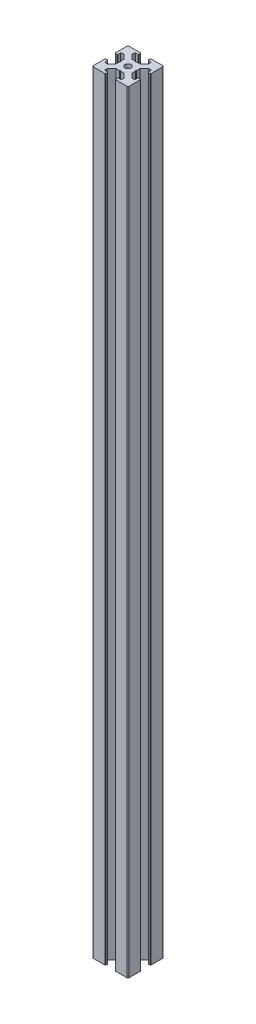
from build123d import *

# Parameters (mm, degrees)
BOSS_EXTRUDE1_DEPTH = 649
FILLET1_R           = 1
SKETCH4_R           = 2.5
CUT_EXTRUDE1_DEPTH  = 650
FILLET2_R           = 0.5


with BuildPart() as part:
    # Sketch3 → Boss-Extrude1 (new body)
    with BuildSketch(Plane(origin=(0, 0, 0), x_dir=(1, 0, 0), z_dir=(0, 1, 0))):
        with BuildLine():
            Line((11, 27.75), (11, 29.5))
            ThreePointArc((11, 29.5), (10.646446609, 29.646446609), (10.5, 30))
            Line((10.5, 30), (0, 30))
            Line((0, 30), (0, 19.5))
            ThreePointArc((0, 19.5), (0.353553391, 19.353553391), (0.5, 19))
            Line((0.5, 19), (2.25, 19))
            Line((2.25, 19), (2.25, 22))
            Line((2.25, 22), (4.5, 22))
            Line((4.5, 22), (8.25, 18.5))
            Line((8.25, 18.5), (8.25, 15.5))
            Line((8.25, 15.5), (8.75, 15))
            Line((8.75, 15), (8.25, 14.5))
            Line((8.25, 14.5), (8.25, 11.5))
            Line((8.25, 11.5), (4.5, 8))
            Line((4.5, 8), (2.25, 8))
            Line((2.25, 8), (2.25, 11))
            Line((2.25, 11), (0.5, 11))
            ThreePointArc((0.5, 11), (0.353553391, 10.646446609), (0, 10.5))
            Line((0, 10.5), (0, 0))
            Line((0, 0), (10.5, 0))
            ThreePointArc((10.5, 0), (10.646446609, 0.353553391), (11, 0.5))
            Line((11, 0.5), (11, 2.25))
            Line((11, 2.25), (8, 2.25))
            Line((8, 2.25), (8, 4.5))
            Line((8, 4.5), (11.5, 8.25))
            Line((11.5, 8.25), (14.5, 8.25))
            Line((14.5, 8.25), (15, 8.75))
            Line((15, 8.75), (15.5, 8.25))
            Line((15.5, 8.25), (18.5, 8.25))
            Line((18.5, 8.25), (22, 4.5))
            Line((22, 4.5), (22, 2.25))
            Line((22, 2.25), (19, 2.25))
            Line((19, 2.25), (19, 0.5))
            ThreePointArc((19, 0.5), (19.353553391, 0.353553391), (19.5, 0))
            Line((19.5, 0), (30, 0))
            Line((30, 0), (30, 10.5))
            ThreePointArc((30, 10.5), (29.646446609, 10.646446609), (29.5, 11))
            Line((29.5, 11), (27.75, 11))
            Line((27.75, 11), (27.75, 8))
            Line((27.75, 8), (25.5, 8))
            Line((25.5, 8), (21.75, 11.5))
            Line((21.75, 11.5), (21.75, 14.5))
            Line((21.75, 14.5), (21.25, 15))
            Line((21.25, 15), (21.75, 15.5))
            Line((21.75, 15.5), (21.75, 18.5))
            Line((21.75, 18.5), (25.5, 22))
            Line((25.5, 22), (27.75, 22))
            Line((27.75, 22), (27.75, 19))
            Line((27.75, 19), (29.5, 19))
            ThreePointArc((29.5, 19), (29.646446609, 19.353553391), (30, 19.5))
            Line((30, 19.5), (30, 30))
            Line((30, 30), (19.5, 30))
            ThreePointArc((19.5, 30), (19.353553391, 29.646446609), (19, 29.5))
            Line((19, 29.5), (19, 27.75))
            Line((19, 27.75), (22, 27.75))
            Line((22, 27.75), (22, 25.5))
            Line((22, 25.5), (18.5, 21.75))
            Line((18.5, 21.75), (15.5, 21.75))
            Line((15.5, 21.75), (15, 21.25))
            Line((15, 21.25), (14.5, 21.75))
            Line((14.5, 21.75), (11.5, 21.75))
            Line((11.5, 21.75), (8, 25.5))
            Line((8, 25.5), (8, 27.75))
            Line((8, 27.75), (11, 27.75))
        make_face()
    extrude(amount=BOSS_EXTRUDE1_DEPTH)

    # Fillet1
    fillet1_edges = [part.edges().sort_by_distance(p)[0] for p in [
        (30, 324.5, 0),
        (0, 324.5, 0),
        (0, 324.5, -30),
        (30, 324.5, -30),
    ]]
    fillet(fillet1_edges, radius=FILLET1_R)

    # Sketch4 → Cut-Extrude1 (cut, through all)
    with BuildSketch(Plane(origin=(0, 649, 0), x_dir=(1, 0, 0), z_dir=(0, 1, 0))):
        with Locations((15, 15)):
            Circle(SKETCH4_R)
    extrude(amount=-CUT_EXTRUDE1_DEPTH, mode=Mode.SUBTRACT)

    # Fillet2
    fillet2_edges = [part.edges().sort_by_distance(p)[0] for p in [
        (27.75, 324.5, -19),
        (27.75, 324.5, -22),
        (21.75, 324.5, -15.5),
        (21.75, 324.5, -14.5),
        (27.75, 324.5, -8),
        (27.75, 324.5, -11),
        (19, 324.5, -2.25),
        (22, 324.5, -2.25),
        (15.5, 324.5, -8.25),
        (14.5, 324.5, -8.25),
        (8, 324.5, -2.25),
        (11, 324.5, -2.25),
        (2.25, 324.5, -11),
        (2.25, 324.5, -8),
        (8.25, 324.5, -14.5),
        (8.25, 324.5, -15.5),
        (2.25, 324.5, -22),
        (2.25, 324.5, -19),
        (11, 324.5, -27.75),
        (8, 324.5, -27.75),
        (14.5, 324.5, -21.75),
        (15.5, 324.5, -21.75),
        (22, 324.5, -27.75),
        (19, 324.5, -27.75),
    ]]
    fillet(fillet2_edges, radius=FILLET2_R)


solid = part.part
